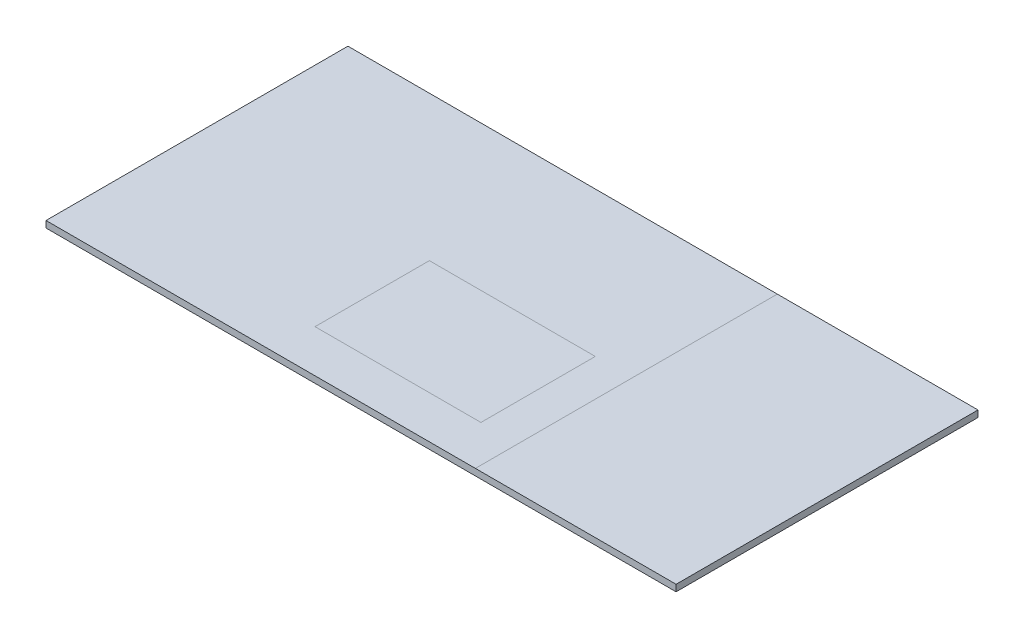
from build123d import *

# Parameters (mm, degrees)
IZIM2_W                     = 1920
IZIM2_H                     = 920
Y_KSEKLIK_EKSTR_ZYON2_DEPTH = 20


with BuildPart() as part:
    # Çizim2 → Yükseklik-Ekstrüzyon2 (new body)
    with BuildSketch(Plane(origin=(0, 0, 0), x_dir=(1, 0, 0), z_dir=(0, 1, 0))):
        with Locations((960, 460)):
            Rectangle(IZIM2_W, IZIM2_H)
    extrude(amount=Y_KSEKLIK_EKSTR_ZYON2_DEPTH)


solid = part.part
